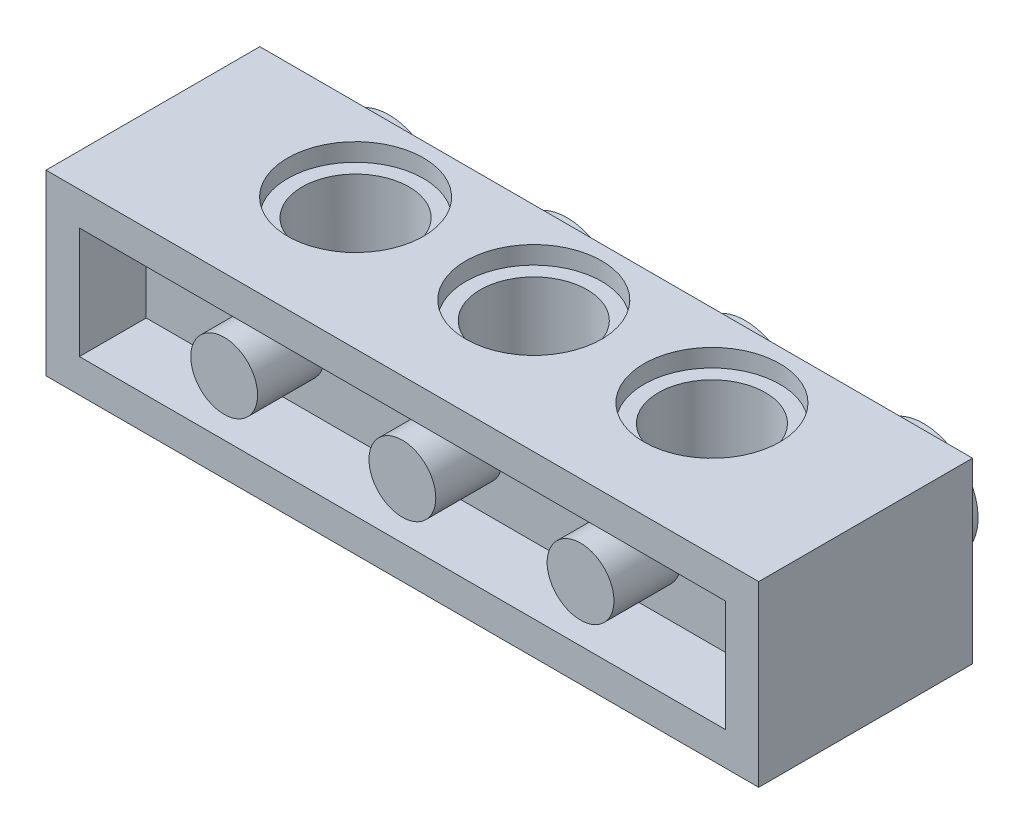
from build123d import *

# Parameters (mm, degrees)
SKETCH1_W           = 32
SKETCH1_H           = 9.6
BOSS_EXTRUDE3_DEPTH = 8
SKETCH2_R           = 2.4
CUT_EXTRUDE6_DEPTH  = 7.8
SKETCH3_R           = 3.05
CUT_EXTRUDE7_DEPTH  = 0.8
SKETCH4_R           = 3.05
CUT_EXTRUDE8_DEPTH  = 0.8
SKETCH5_R           = 2.45
BOSS_EXTRUDE4_DEPTH = 1.8
SKETCH6_W           = 29
SKETCH6_H           = 5
CUT_EXTRUDE9_DEPTH  = 3
SKETCH7_R           = 1.5
BOSS_EXTRUDE5_DEPTH = 3


with BuildPart() as part:
    # Sketch1 → Boss-Extrude3 (new body)
    with BuildSketch(Plane(origin=(0, 0, 0), x_dir=(1, 0, 0), z_dir=(0, 1, 0))):
        with Locations((0, -1.1)):
            Rectangle(SKETCH1_W, SKETCH1_H)
    extrude(amount=BOSS_EXTRUDE3_DEPTH)

    # Sketch2 → Cut-Extrude6 (cut)
    with BuildSketch(Plane(origin=(0, 8, 0), x_dir=(1, 0, 0), z_dir=(0, 1, 0))):
        Circle(SKETCH2_R)
        with Locations((8, 0)):
            Circle(SKETCH2_R)
        with Locations((-8, 0)):
            Circle(SKETCH2_R)
    extrude(amount=-CUT_EXTRUDE6_DEPTH, mode=Mode.SUBTRACT)

    # Sketch3 → Cut-Extrude7 (cut)
    with BuildSketch(Plane(origin=(0, 8, 0), x_dir=(1, 0, 0), z_dir=(0, 1, 0))):
        Circle(SKETCH3_R)
        with Locations((8, 0)):
            Circle(SKETCH3_R)
        with Locations((-8, 0)):
            Circle(SKETCH3_R)
    extrude(amount=-CUT_EXTRUDE7_DEPTH, mode=Mode.SUBTRACT)

    # Sketch4 → Cut-Extrude8 (cut)
    with BuildSketch(Plane.XZ):
        Circle(SKETCH4_R)
        with Locations((8, 0)):
            Circle(SKETCH4_R)
        with Locations((-8, 0)):
            Circle(SKETCH4_R)
    extrude(amount=-CUT_EXTRUDE8_DEPTH, mode=Mode.SUBTRACT)

    # Sketch5 → Boss-Extrude4 (add)
    with BuildSketch(Plane(origin=(0, 0, -3.7), x_dir=(-1, 0, 0), z_dir=(0, 0, -1))):
        with Locations((-12, 4)):
            Circle(SKETCH5_R)
        with Locations((-4, 4)):
            Circle(SKETCH5_R)
        with Locations((4, 4)):
            Circle(SKETCH5_R)
        with Locations((12, 4)):
            Circle(SKETCH5_R)
    extrude(amount=BOSS_EXTRUDE4_DEPTH)

    # Sketch6 → Cut-Extrude9 (cut)
    with BuildSketch(Plane.XY.offset(5.9)):
        with Locations((0, 4)):
            Rectangle(SKETCH6_W, SKETCH6_H)
    extrude(amount=-CUT_EXTRUDE9_DEPTH, mode=Mode.SUBTRACT)

    # Sketch7 → Boss-Extrude5 (add)
    with BuildSketch(Plane.XY.offset(2.9)):
        with Locations((-8, 4)):
            Circle(SKETCH7_R)
        with Locations((0, 4)):
            Circle(SKETCH7_R)
        with Locations((8, 4)):
            Circle(SKETCH7_R)
    extrude(amount=BOSS_EXTRUDE5_DEPTH)


solid = part.part
